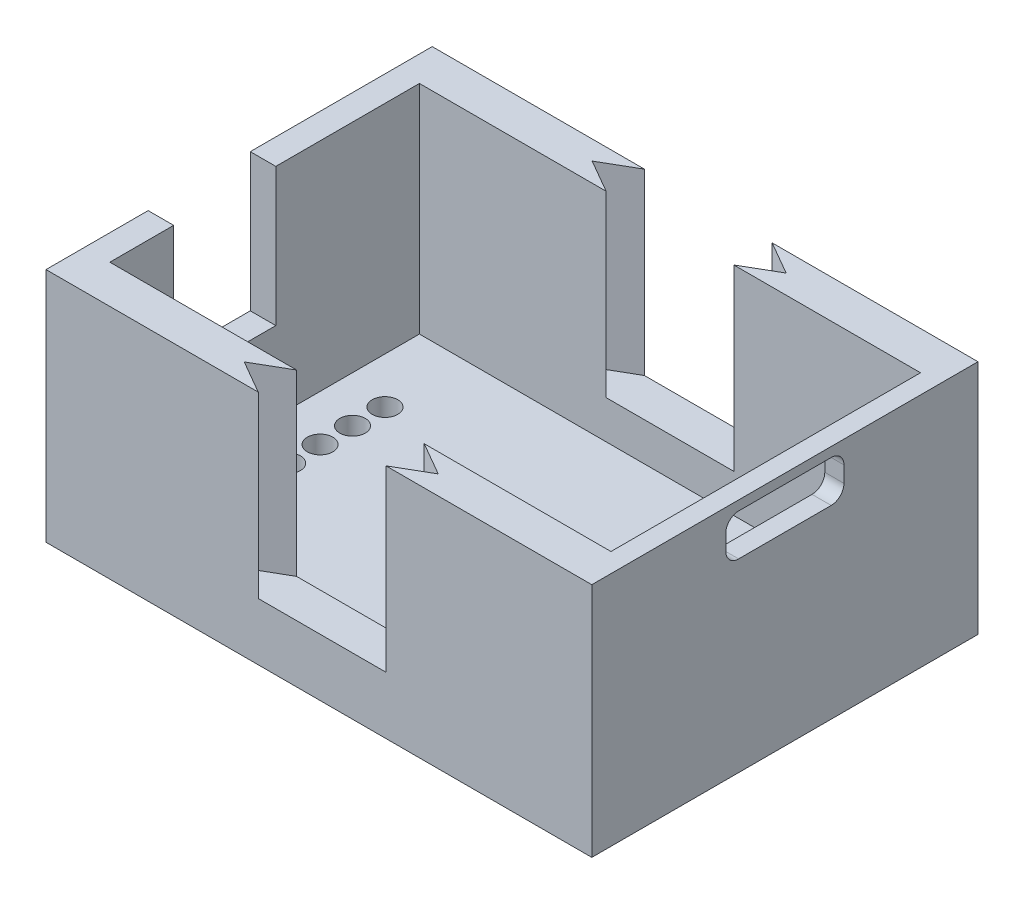
from build123d import *

# Parameters (mm, degrees)
SKETCH1_W           = 39.25
SKETCH1_H           = 24.25
BOSS_EXTRUDE1_DEPTH = 1.5
SKETCH2_W           = 42.75
SKETCH2_H           = 30.25
SKETCH2_W_2         = 39.25
SKETCH2_H_2         = 24.25
BOSS_EXTRUDE2_DEPTH = 18.5
SKETCH3_W           = 2
SKETCH3_H           = 8
CUT_EXTRUDE1_DEPTH  = 10.8
CUT_EXTRUDE2_REACH  = 44.75
CUT_EXTRUDE3_DEPTH  = 14
SKETCH7_R           = 1
CUT_EXTRUDE4_DEPTH  = 2.5


with BuildPart() as part:
    # Sketch1 → Boss-Extrude1 (new body)
    with BuildSketch(Plane(origin=(0, 0, 0), x_dir=(1, 0, 0), z_dir=(0, 1, 0))):
        Rectangle(SKETCH1_W, SKETCH1_H)
    extrude(amount=BOSS_EXTRUDE1_DEPTH)

    # Sketch2 → Boss-Extrude2 (add)
    with BuildSketch(Plane(origin=(0, 0, 0), x_dir=(1, 0, 0), z_dir=(0, 1, 0))):
        with Locations((-0.25, 0)):
            Rectangle(SKETCH2_W, SKETCH2_H)
        Rectangle(SKETCH2_W_2, SKETCH2_H_2, mode=Mode.SUBTRACT)
    extrude(amount=BOSS_EXTRUDE2_DEPTH)

    # Sketch3 → Cut-Extrude1 (cut)
    with BuildSketch(Plane(origin=(0, 18.5, 0), x_dir=(1, 0, 0), z_dir=(0, 1, 0))):
        with Locations((-20.625, -3.125)):
            Rectangle(SKETCH3_W, SKETCH3_H)
    extrude(amount=-CUT_EXTRUDE1_DEPTH, mode=Mode.SUBTRACT)

    # Sketch4 → Cut-Extrude2 (cut, up to next)
    with BuildSketch(Plane(origin=(21.125, 0, 0), x_dir=(0, 0, -1), z_dir=(1, 0, 0)), mode=Mode.PRIVATE) as cut_extrude2_sk1:
        with BuildLine():
            Line((-3.625, 14.5), (3.625, 14.5))
            ThreePointArc((3.625, 14.5), (4.332106781, 14.792893219), (4.625, 15.5))
            Line((4.625, 15.5), (4.625, 16.75))
            ThreePointArc((4.625, 16.75), (4.332106781, 17.457106781), (3.625, 17.75))
            Line((3.625, 17.75), (-3.625, 17.75))
            ThreePointArc((-3.625, 17.75), (-4.332106781, 17.457106781), (-4.625, 16.75))
            Line((-4.625, 16.75), (-4.625, 15.5))
            ThreePointArc((-4.625, 15.5), (-4.332106781, 14.792893219), (-3.625, 14.5))
        make_face()
    cut_extrude2_tool1 = extrude(cut_extrude2_sk1.sketch, amount=-CUT_EXTRUDE2_REACH, mode=Mode.PRIVATE) & part.part
    add(cut_extrude2_tool1.solids().sort_by_distance((21.125, 16.125, 0))[0], mode=Mode.SUBTRACT)

    # Sketch6 → Cut-Extrude3 (cut)
    with BuildSketch(Plane(origin=(0, 18.5, 0), x_dir=(1, 0, 0), z_dir=(0, 1, 0))):
        Polygon((-5, 15.125), (-7.598076211, 13.625), (-5, 12.125), (5, 12.125), (7.598076211, 13.625), (5, 15.125), align=None)
        Polygon((-7.598076211, -13.625), (-5, -12.125), (5, -12.125), (7.598076211, -13.625), (5, -15.125), (-5, -15.125), align=None)
    extrude(amount=-CUT_EXTRUDE3_DEPTH, mode=Mode.SUBTRACT)

    # Sketch7 → Cut-Extrude4 (cut, through all)
    with BuildSketch(Plane(origin=(0, 1.5, 0), x_dir=(1, 0, 0), z_dir=(0, 1, 0))):
        with Locations((-16.025, -6.875)):
            Circle(SKETCH7_R)
        with Locations((-16.025, -4.335)):
            Circle(SKETCH7_R)
        with Locations((-16.025, -1.795)):
            Circle(SKETCH7_R)
        with Locations((-16.025, 0.745)):
            Circle(SKETCH7_R)
        with Locations((-16.025, 3.285)):
            Circle(SKETCH7_R)
        with Locations((-16.025, 5.825)):
            Circle(SKETCH7_R)
    extrude(amount=-CUT_EXTRUDE4_DEPTH, mode=Mode.SUBTRACT)


solid = part.part
